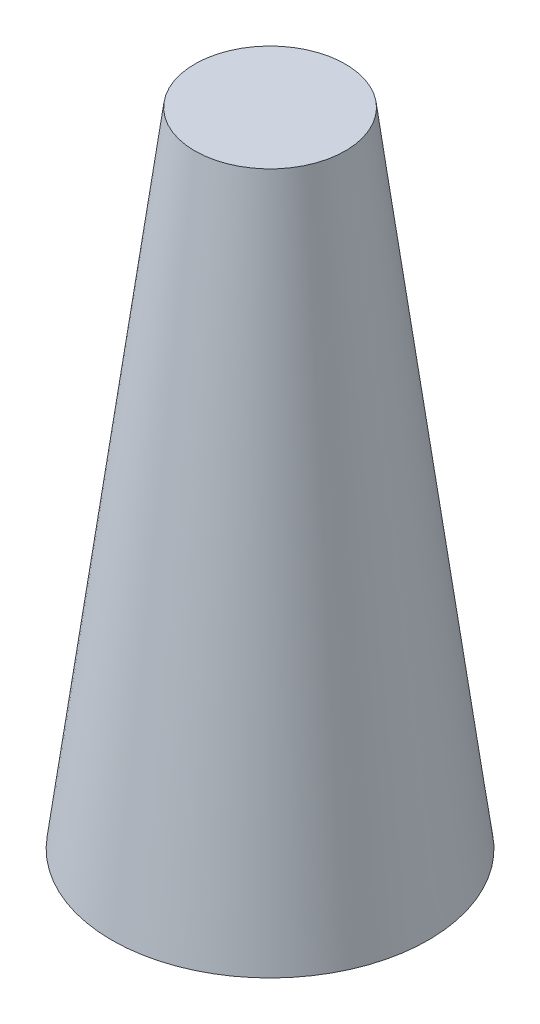
from build123d import *

# Parameters (mm, degrees)
SKETCH1_R = 126
SKETCH2_R = 59.9


with BuildPart() as part:
    # Sketch1 → Loft1 section 0
    with BuildSketch(Plane(origin=(0, 0, 0), x_dir=(1, 0, 0), z_dir=(0, 1, 0))):
        Circle(SKETCH1_R)
    # Sketch2 → Loft1 section 1
    with BuildSketch(Plane(origin=(0, 510.8, 0), x_dir=(1, 0, 0), z_dir=(0, 1, 0))):
        Circle(SKETCH2_R)
    loft()


solid = part.part
